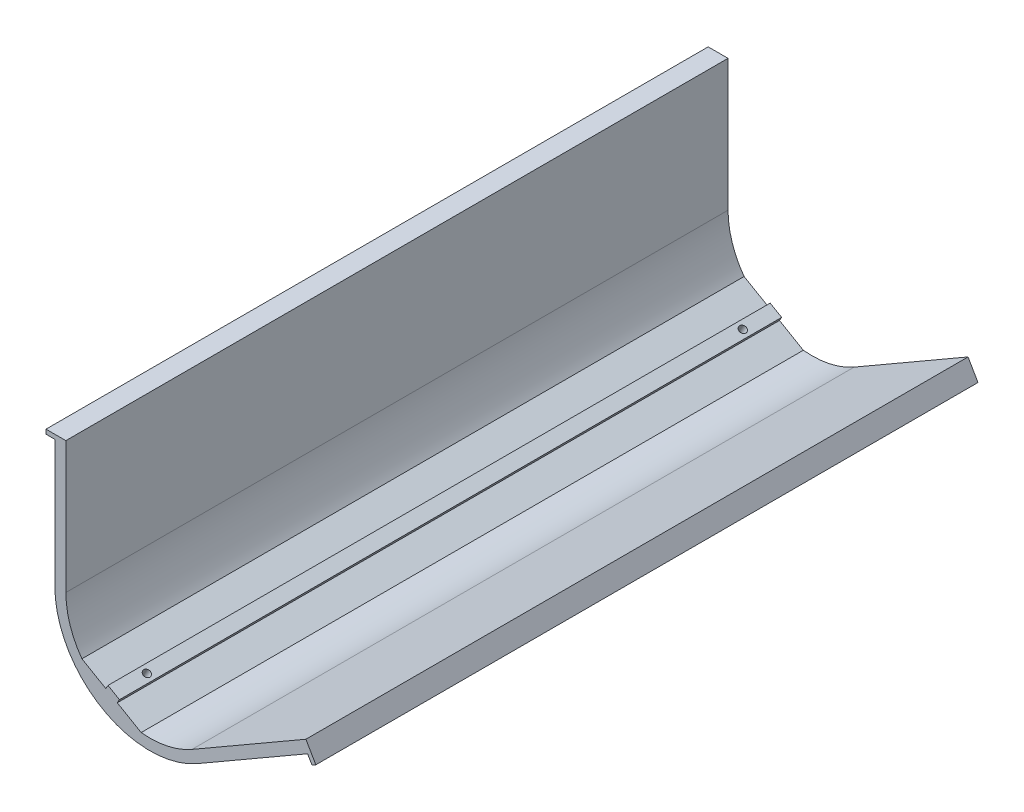
from build123d import *

# Parameters (mm, degrees)
BOSS_EXTRUDE1_DEPTH = 300
SKETCH3_R           = 1.6
CUT_EXTRUDE1_DEPTH  = 27.070508076
CUT_EXTRUDE2_START  = -2
SKETCH4_R           = 2.875
CUT_EXTRUDE2_DEPTH  = 25.070508162
SKETCH5_W           = 6
SKETCH5_H           = 300
SKETCH5_R           = 1.6
BOSS_EXTRUDE2_DEPTH = 2


with BuildPart() as part:
    # Sketch2 → Boss-Extrude1 (new body)
    with BuildSketch(Plane.XY):
        with BuildLine():
            Line((-10, 0), (-10, 57.592991829))
            Line((-10, 57.592991829), (-14, 57.592991829))
            Line((-14, 57.592991829), (-14, 59.592991829))
            Line((-14, 59.592991829), (-10, 59.592991829))
            Line((-10, 59.592991829), (-5, 59.592991829))
            Line((-5, 59.592991829), (-5, 0))
            ThreePointArc((-5, 0), (-3.13691529, -11.76748288), (2.270101024, -22.383928263))
            Line((2.270101024, -22.383928263), (29.120915128, -37.886253013))
            ThreePointArc((29.120915128, -37.886253013), (41.018534684, -37.260643809), (52.141016151, -32.990381057))
            Line((52.141016151, -32.990381057), (103.750060963, -3.193885142))
            Line((103.750060963, -3.193885142), (106.250060963, -7.524012161))
            Line((106.250060963, -7.524012161), (108.250060963, -10.988113776))
            Line((108.250060963, -10.988113776), (106.518010155, -11.988113776))
            Line((106.518010155, -11.988113776), (104.518010155, -8.524012161))
            Line((104.518010155, -8.524012161), (54.641016151, -37.320508076))
            ThreePointArc((54.641016151, -37.320508076), (11.547005384, -37.320508076), (-10, 0))
        make_face()
    extrude(amount=BOSS_EXTRUDE1_DEPTH)

    # Sketch3 → Cut-Extrude1 (cut, through all)
    with BuildSketch(Plane(origin=(-9.125, -15.804963619, 0), x_dir=(0.866025404, -0.5, 0), z_dir=(0.5, 0.866025404, 0))):
        with Locations((28.660254038, -15)):
            Circle(SKETCH3_R)
        with Locations((28.660254038, -285)):
            Circle(SKETCH3_R)
    extrude(amount=-CUT_EXTRUDE1_DEPTH, mode=Mode.SUBTRACT)

    # Sketch4 → Cut-Extrude2 (cut, through all)
    with BuildSketch(Plane(origin=(-9.125, -15.804963619, 0), x_dir=(0.866025404, -0.5, 0), z_dir=(0.5, 0.866025404, 0)).offset(CUT_EXTRUDE2_START)):
        with Locations((28.660254038, -15)):
            Circle(SKETCH4_R)
        with Locations((28.660254038, -285)):
            Circle(SKETCH4_R)
    extrude(amount=-CUT_EXTRUDE2_DEPTH, mode=Mode.SUBTRACT)

    # Sketch5 → Boss-Extrude2 (add)
    with BuildSketch(Plane(origin=(-9.125, -15.804963619, 0), x_dir=(0.866025404, -0.5, 0), z_dir=(0.5, 0.866025404, 0))):
        with Locations((28.660254038, -150)):
            Rectangle(SKETCH5_W, SKETCH5_H)
        with Locations((28.660254038, -15)):
            Circle(SKETCH5_R, mode=Mode.SUBTRACT)
        with Locations((28.660254038, -285)):
            Circle(SKETCH5_R, mode=Mode.SUBTRACT)
    extrude(amount=BOSS_EXTRUDE2_DEPTH)


solid = part.part
